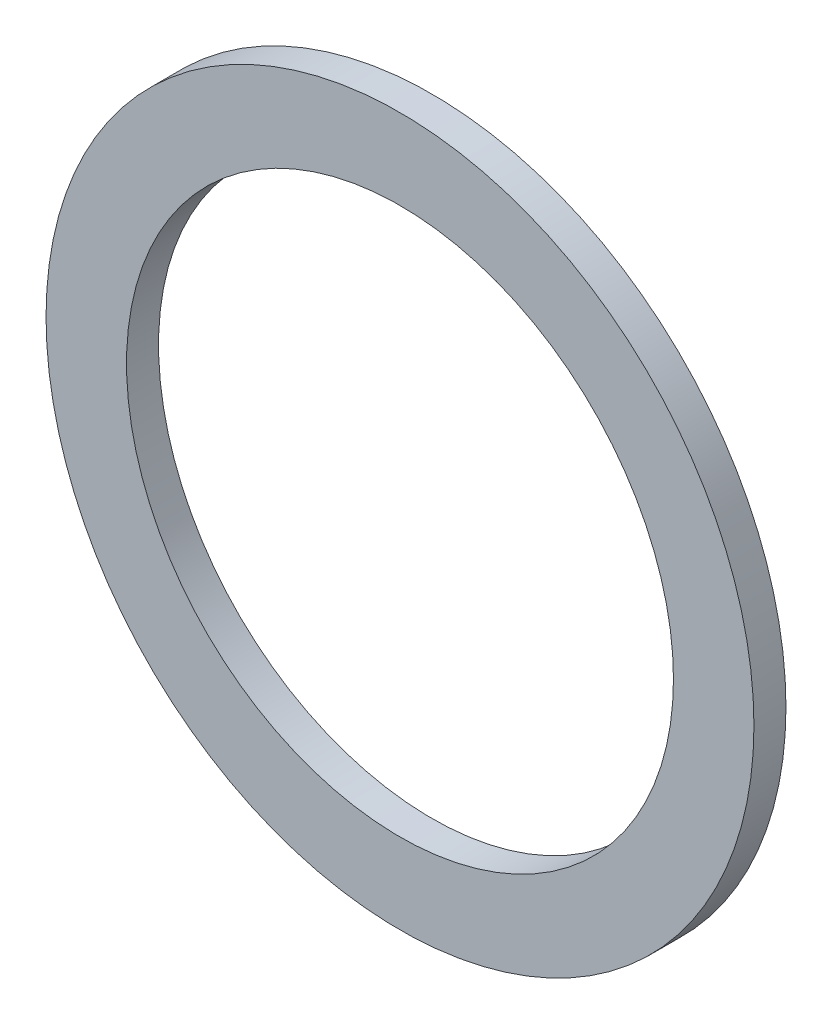
from build123d import *

# Parameters (mm, degrees)
SKETCH3_R           = 19.35
SKETCH3_R_2         = 14.95
BOSS_EXTRUDE1_DEPTH = 1.75


with BuildPart() as part:
    # Sketch3 → Boss-Extrude1 (new body)
    with BuildSketch(Plane.XY):
        Circle(SKETCH3_R)
        Circle(SKETCH3_R_2, mode=Mode.SUBTRACT)
    extrude(amount=BOSS_EXTRUDE1_DEPTH)


solid = part.part
